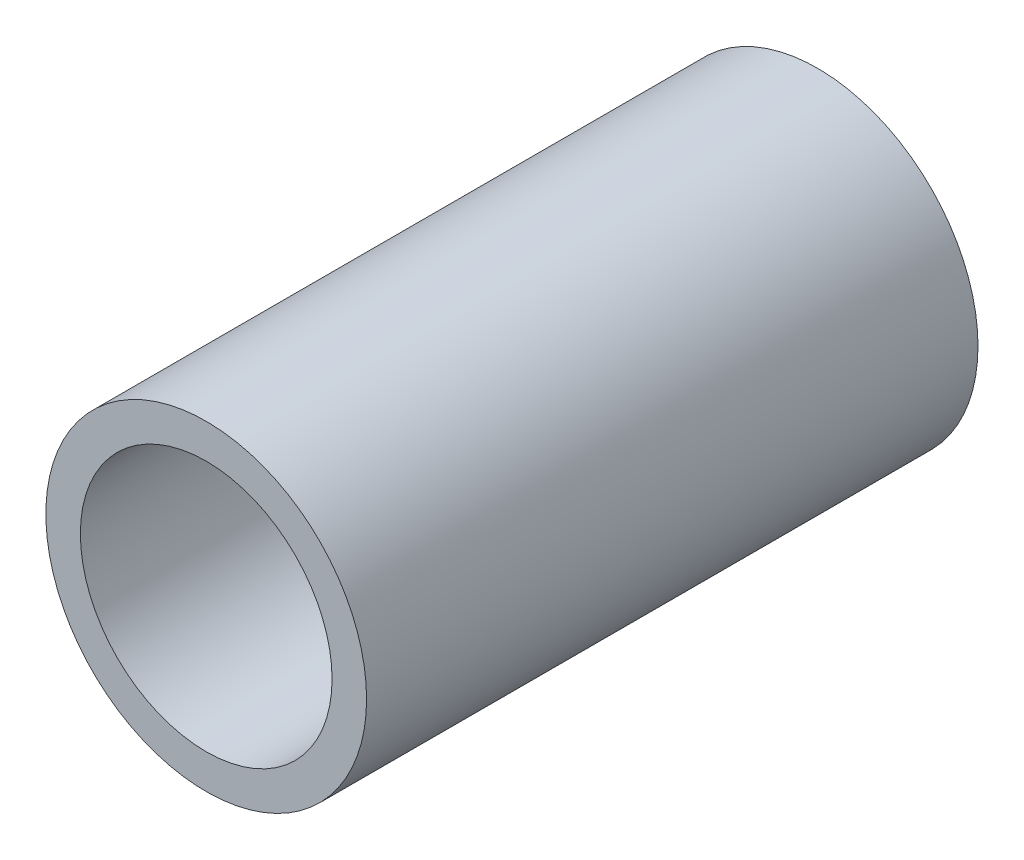
from build123d import *

# Parameters (mm, degrees)
SKETCH3_R                = 13.335
SKETCH3_R_2              = 10.4648
BOSS_EXTRUDE1_DEPTH      = 762
BOSS_EXTRUDE1_DEPTH_BACK = 762
SKETCH4_R                = 13.335
CUT_EXTRUDE2_DEPTH       = 1473.158969


with BuildPart() as part:
    # Sketch3 → Boss-Extrude1 (new body, two sides)
    with BuildSketch(Plane.XY) as boss_extrude1_sk:
        Circle(SKETCH3_R)
        Circle(SKETCH3_R_2, mode=Mode.SUBTRACT)
    extrude(amount=BOSS_EXTRUDE1_DEPTH)
    extrude(boss_extrude1_sk.sketch, amount=-BOSS_EXTRUDE1_DEPTH_BACK)

    # Sketch4 → Cut-Extrude2 (cut)
    with BuildSketch(Plane.XY.offset(762)):
        Circle(SKETCH4_R)
    extrude(amount=-CUT_EXTRUDE2_DEPTH, mode=Mode.SUBTRACT)


solid = part.part
